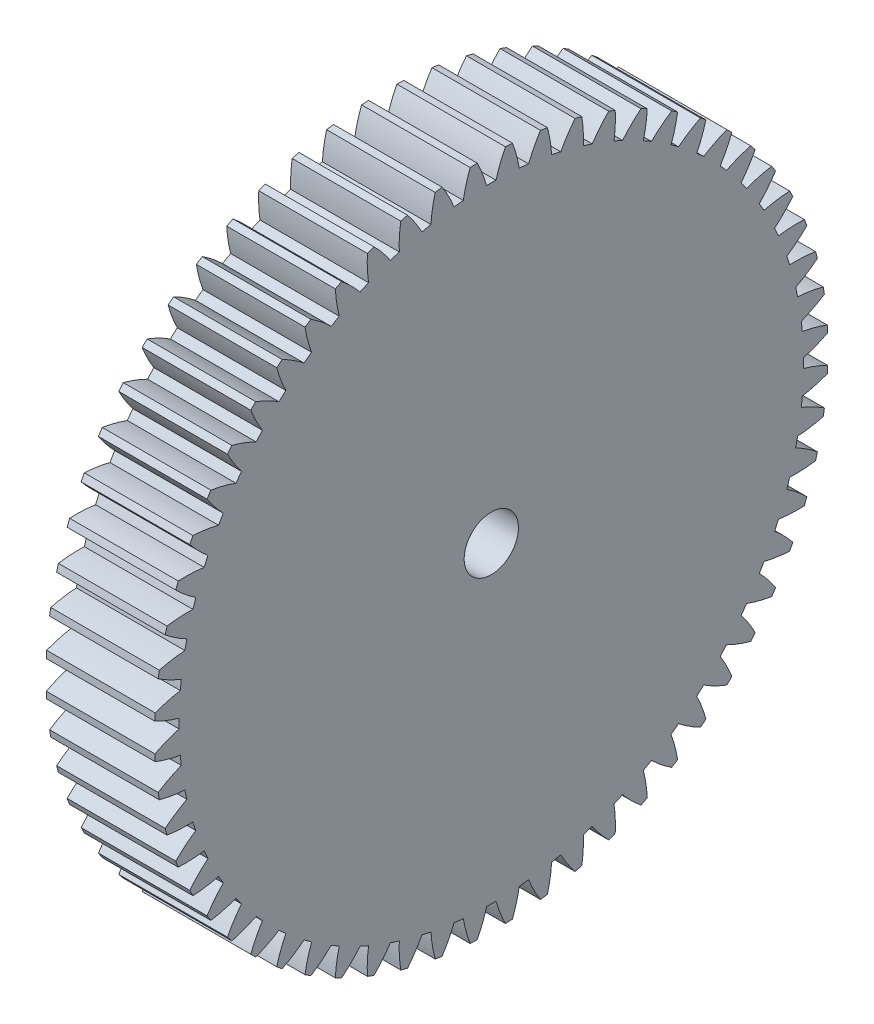
from build123d import *

# Parameters (mm, degrees)
BASPROSKE_W     = 10
BASPROSKE_H     = 31
TOOTHCUT_DEPTH  = 45.966654312
TEETHCUTS_COUNT = 60
TEETHCUTS_ANGLE = 354
BORSKE_R        = 2.5
BORE_DEPTH      = 50.0000508


with BuildPart() as part:
    # BasProSke → Base-Revolve (revolve)
    with BuildSketch(Plane(origin=(0, 0, 0), x_dir=(1, 0, 0), z_dir=(0, 1, 0)), mode=Mode.PRIVATE) as base_revolve_sk:
        with Locations((5, 15.5)):
            Rectangle(BASPROSKE_W, BASPROSKE_H)
    revolve(base_revolve_sk.sketch.rotate(Axis((-10, 0, 0), (1, 0, 0)), 180), axis=Axis((-10, 0, 0), (1, 0, 0)))

    # TooCutSke → ToothCut (cut, through all)
    with BuildSketch(Plane(origin=(0, 0, 0), x_dir=(0, 0, -1), z_dir=(1, 0, 0))):
        with BuildLine():
            ThreePointArc((0.430151971, 28.745781782), (0, 28.749), (-0.430151971, 28.745781782))
            ThreePointArc((-0.430151971, 28.745781782), (-0.81454129, 29.893990802), (-1.312684569, 30.997617721))
            ThreePointArc((-1.312684569, 30.997617721), (0, 31.0254), (1.312684569, 30.997617721))
            ThreePointArc((1.312684569, 30.997617721), (0.81454129, 29.893990802), (0.430151971, 28.745781782))
        make_face()
    toothcut = extrude(amount=TOOTHCUT_DEPTH, mode=Mode.SUBTRACT)

    # TeethCuts: ToothCut ×60 about axis
    teethcuts_axis = Axis((-10, 0, 0), (1, 0, 0))
    for i in range(1, TEETHCUTS_COUNT):
        add(toothcut.rotate(teethcuts_axis, i * TEETHCUTS_ANGLE / (TEETHCUTS_COUNT - 1)), mode=Mode.SUBTRACT)

    # BorSke → Bore (cut, symmetric)
    with BuildSketch(Plane(origin=(0, 0, 0), x_dir=(0, 0, -1), z_dir=(1, 0, 0))):
        with Locations(Location((0, 0, 0), (0, 0, 180))):
            Circle(BORSKE_R)
    extrude(amount=BORE_DEPTH, both=True, mode=Mode.SUBTRACT)


solid = part.part
